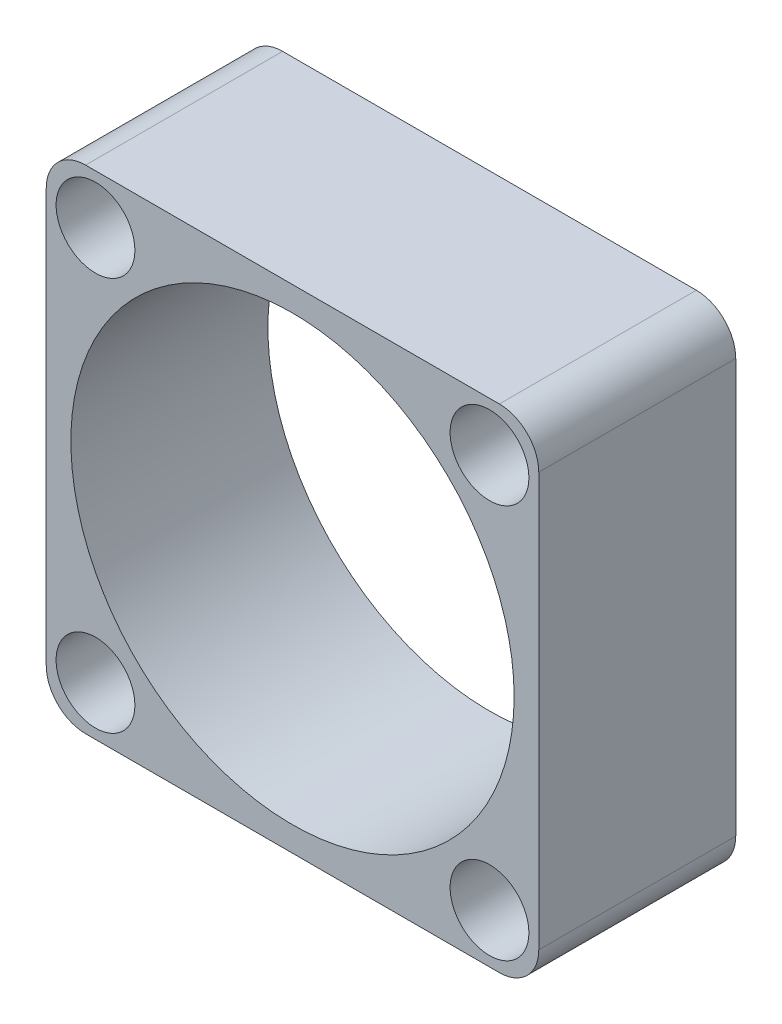
from build123d import *

# Parameters (mm, degrees)
SKETCH1_W           = 25
SKETCH1_H           = 25
BOSS_EXTRUDE1_DEPTH = 10
SKETCH3_R           = 11.25
SKETCH3_R_2         = 2
CUT_EXTRUDE1_DEPTH  = 10
FILLET1_R           = 2


with BuildPart() as part:
    # Sketch1 → Boss-Extrude1 (new body)
    with BuildSketch(Plane.XY):
        with Locations((12.5, 12.5)):
            Rectangle(SKETCH1_W, SKETCH1_H)
    extrude(amount=BOSS_EXTRUDE1_DEPTH)

    # Sketch3 → Cut-Extrude1 (cut)
    with BuildSketch(Plane.XY.offset(10)):
        with Locations((12.5, 12.5)):
            Circle(SKETCH3_R)
        with Locations((2.5, 22.5)):
            Circle(SKETCH3_R_2)
        with Locations((2.5, 2.5)):
            Circle(SKETCH3_R_2)
        with Locations((22.5, 2.5)):
            Circle(SKETCH3_R_2)
        with Locations((22.5, 22.5)):
            Circle(SKETCH3_R_2)
    extrude(amount=-CUT_EXTRUDE1_DEPTH, mode=Mode.SUBTRACT)

    # Fillet1
    fillet1_edges = [part.edges().sort_by_distance(p)[0] for p in [
        (0, 25, 5),
        (25, 25, 5),
        (25, 0, 5),
        (0, 0, 5),
    ]]
    fillet(fillet1_edges, radius=FILLET1_R)


solid = part.part
